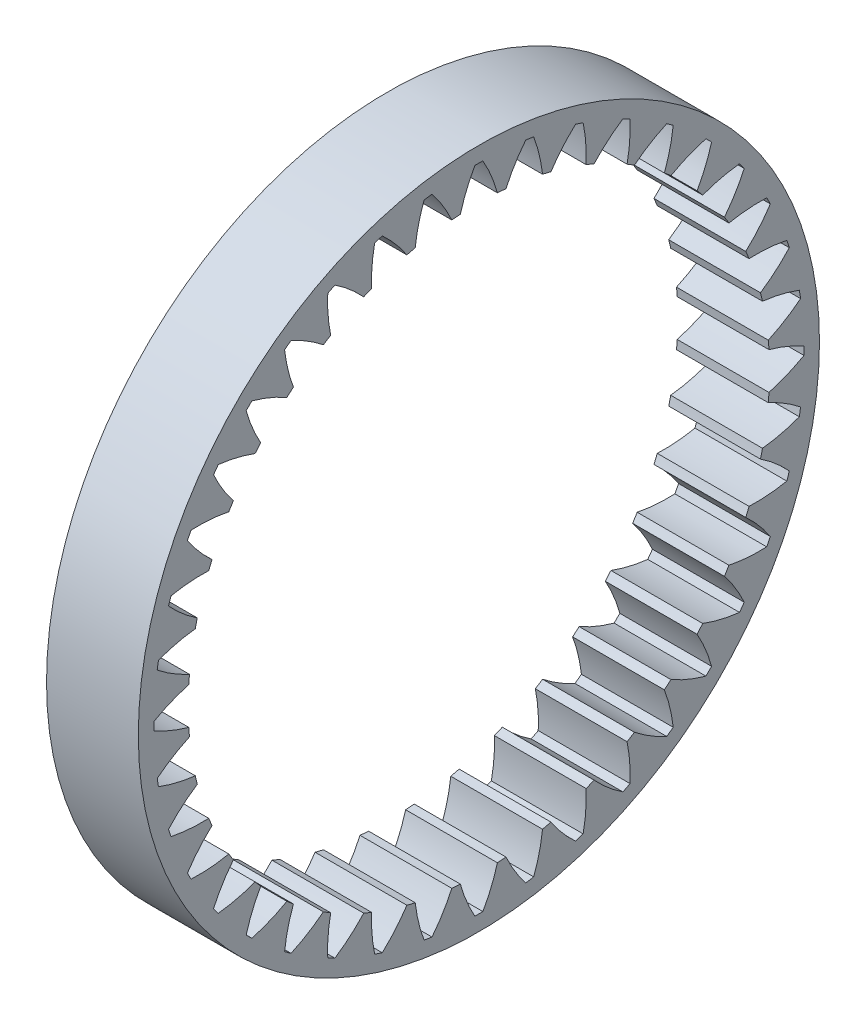
from build123d import *

# Parameters (mm, degrees)
BASPROSKE_W         = 12
BASPROSKE_H         = 4.5264
TOOTHCUT_DEPTH      = 62.326905954
TEETHCUTS_COUNT     = 40
SKETCH2_R           = 44.5264
SKETCH2_R_2         = 42.5264
EXTRUDE_THIN3_DEPTH = 12


with BuildPart() as part:
    # BasProSke → Base-Revolve (revolve)
    with BuildSketch(Plane(origin=(0, 0, 0), x_dir=(1, 0, 0), z_dir=(0, 1, 0)), mode=Mode.PRIVATE) as base_revolve_sk:
        with Locations((6, 40.2632)):
            Rectangle(BASPROSKE_W, BASPROSKE_H)
    revolve(base_revolve_sk.sketch.rotate(Axis((-10, 0, 0), (1, 0, 0)), 180), axis=Axis((-10, 0, 0), (1, 0, 0)))

    # TooCutSke → ToothCut (cut, through all)
    with BuildSketch(Plane(origin=(0, 0, 0), x_dir=(0, 0, -1), z_dir=(1, 0, 0))):
        with BuildLine():
            ThreePointArc((2.427265626, 37.896947459), (1.618641911, 40.256878641), (0.522524415, 42.497787816))
            ThreePointArc((0.522524415, 42.497787816), (0, 42.501), (-0.522524415, 42.497787816))
            ThreePointArc((-0.522524415, 42.497787816), (-1.618641911, 40.256878641), (-2.427265626, 37.896947459))
            ThreePointArc((-2.427265626, 37.896947459), (0, 37.9746), (2.427265626, 37.896947459))
        make_face()
    toothcut = extrude(amount=TOOTHCUT_DEPTH, mode=Mode.SUBTRACT)

    # TeethCuts: ToothCut ×40 about axis
    teethcuts_axis = Axis((0, 0, 0), (1, 0, 0))
    for i in range(1, TEETHCUTS_COUNT):
        add(toothcut.rotate(teethcuts_axis, i * 360 / TEETHCUTS_COUNT), mode=Mode.SUBTRACT)

    # Sketch2 → Extrude-Thin3 (add, through all)
    with BuildSketch(Plane(origin=(0, 0, 0), x_dir=(0, 0, -1), z_dir=(1, 0, 0))):
        Circle(SKETCH2_R)
        Circle(SKETCH2_R_2, mode=Mode.SUBTRACT)
    extrude(amount=EXTRUDE_THIN3_DEPTH)


solid = part.part
